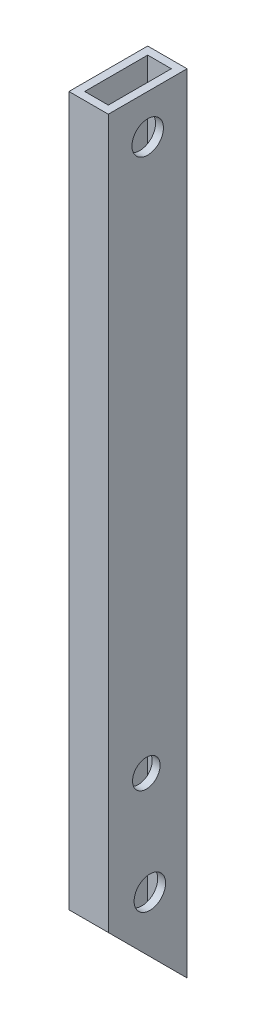
from build123d import *

# Parameters (mm, degrees)
SKETCH1_W           = 10
SKETCH1_H           = 200
BOSS_EXTRUDE1_DEPTH = 20
SHELL1_T            = -2
CUT_EXTRUDE1_DEPTH  = 10
SKETCH4_R           = 4
CUT_EXTRUDE3_DEPTH  = 10
SKETCH5_R           = 4
SKETCH5_R_2         = 3.5
CUT_EXTRUDE4_DEPTH  = 10


with BuildPart() as part:
    # Sketch1 → Boss-Extrude1 (new body)
    with BuildSketch(Plane.XY):
        Rectangle(SKETCH1_W, SKETCH1_H)
    extrude(amount=BOSS_EXTRUDE1_DEPTH)

    # Shell1
    shell1_openings = [part.faces().sort_by_distance(p)[0] for p in [
        (0, 100, 10),
        (0, -100, 10),
    ]]
    offset(amount=SHELL1_T, openings=shell1_openings, kind=Kind.INTERSECTION)

    # Sketch2 → Cut-Extrude1 (cut)
    with BuildSketch(Plane.ZY.offset(5)):
        Polygon((0, -100), (20, -80), (20, -100), align=None)
    extrude(amount=-CUT_EXTRUDE1_DEPTH, mode=Mode.SUBTRACT)

    # Sketch4 → Cut-Extrude3 (cut)
    with BuildSketch(Plane(origin=(5, 0, 0), x_dir=(0, 0, -1), z_dir=(1, 0, 0))):
        with Locations((-10, 90)):
            Circle(SKETCH4_R)
    extrude(amount=-CUT_EXTRUDE3_DEPTH, mode=Mode.SUBTRACT)

    # Sketch5 → Cut-Extrude4 (cut)
    with BuildSketch(Plane(origin=(5, 0, 0), x_dir=(0, 0, -1), z_dir=(1, 0, 0))):
        with Locations((-9.453331646, -76.40453273)):
            Circle(SKETCH5_R)
        with Locations((-10.347176909, -49.772000632)):
            Circle(SKETCH5_R_2)
    extrude(amount=-CUT_EXTRUDE4_DEPTH, mode=Mode.SUBTRACT)


solid = part.part
